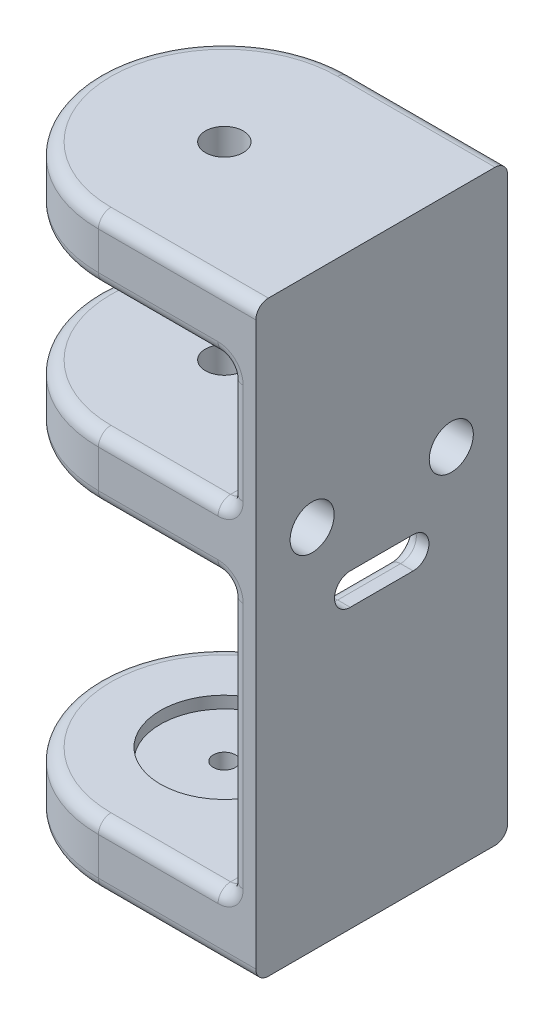
from build123d import *

# Parameters (mm, degrees)
SKETCH2_W           = 4
SKETCH2_H           = 40
BOSS_EXTRUDE1_DEPTH = 93.3
BOSS_EXTRUDE2_DEPTH = 10
SKETCH4_R           = 3
CUT_EXTRUDE4_DEPTH  = 10
SKETCH3_R           = 10.15
CUT_EXTRUDE3_DEPTH  = 1.9
SKETCH6_R           = 1.75
CUT_EXTRUDE6_DEPTH  = 9.1
FILLET2_R           = 2
SKETCH7_R           = 3.5
CUT_EXTRUDE7_DEPTH  = 6.1
CUT_EXTRUDE8_DEPTH  = 46
FILLET3_R           = 2


with BuildPart() as part:
    # Sketch2 → Boss-Extrude1 (new body)
    with BuildSketch(Plane(origin=(0, 0, 0), x_dir=(1, 0, 0), z_dir=(0, 1, 0))):
        Rectangle(SKETCH2_W, SKETCH2_H)
    extrude(amount=BOSS_EXTRUDE1_DEPTH)


with BuildPart() as body_2:
    # Sketch1 → Boss-Extrude2 (new body)
    with BuildSketch(Plane(origin=(0, 93.3, 0), x_dir=(1, 0, 0), z_dir=(0, 1, 0))):
        with BuildLine():
            Line((-23, -20), (-2, -20))
            Line((-2, -20), (-2, 20))
            Line((-2, 20), (-23, 20))
            ThreePointArc((-23, 20), (-43, 0), (-23, -20))
        make_face()
    boss_extrude2 = extrude(amount=-BOSS_EXTRUDE2_DEPTH)

    # Sketch4 → Cut-Extrude4 (cut)
    with BuildSketch(Plane(origin=(0, 93.3, 0), x_dir=(1, 0, 0), z_dir=(0, 1, 0))):
        with Locations((-23, 0)):
            Circle(SKETCH4_R)
    cut_extrude4 = extrude(amount=-CUT_EXTRUDE4_DEPTH, mode=Mode.SUBTRACT)


with BuildPart() as part_1:
    add(part.part)

    # Mirror8: Boss-Extrude2 across plane
    add(boss_extrude2.mirror(Plane.ZX.offset(46.65)))

    # Mirror10: Boss-Extrude2, Cut-Extrude4 across plane
    add(boss_extrude2.mirror(Plane.ZX.offset(73.3)))
    add(cut_extrude4.mirror(Plane.ZX.offset(73.3)), mode=Mode.SUBTRACT)


with BuildPart() as body_2_1:
    add(body_2.part)

    # Combine2: union part
    add(part_1.part)

    # Sketch3 → Cut-Extrude3 (cut)
    with BuildSketch(Plane(origin=(0, 10, 0), x_dir=(1, 0, 0), z_dir=(0, 1, 0))):
        with Locations((-23, 0)):
            Circle(SKETCH3_R)
    extrude(amount=-CUT_EXTRUDE3_DEPTH, mode=Mode.SUBTRACT)

    # Sketch6 → Cut-Extrude6 (cut, through all)
    with BuildSketch(Plane(origin=(0, 8.1, 0), x_dir=(1, 0, 0), z_dir=(0, 1, 0))):
        with Locations((-23, 0)):
            Circle(SKETCH6_R)
    extrude(amount=-CUT_EXTRUDE6_DEPTH, mode=Mode.SUBTRACT)

    # Fillet2
    fillet2_edges = [body_2_1.edges().sort_by_distance(p)[0] for p in [
        (-43, 83.3, 0),
        (-12.5, 83.3, 20),
        (-2, 73.3, -20),
        (-2, 53.3, 0),
        (-2, 31.65, -20),
        (-10.5, 0, -20),
        (-12.5, 53.3, -20),
        (-10.5, 0, 20),
        (-2, 73.3, 20),
        (-12.5, 53.3, 20),
        (-2, 31.65, 20),
        (-43, 0, 0),
        (-2, 10, 0),
        (-12.5, 10, -20),
        (-43, 10, 0),
        (-12.5, 10, 20),
        (-43, 53.3, 0),
        (-2, 63.3, 0),
        (-12.5, 63.3, -20),
        (-43, 63.3, 0),
        (-12.5, 63.3, 20),
        (-2, 83.3, 0),
        (-10.5, 93.3, 20),
        (-43, 93.3, 0),
        (-10.5, 93.3, -20),
        (-12.5, 83.3, -20),
    ]]
    fillet(fillet2_edges, radius=FILLET2_R)

    # Sketch7 → Cut-Extrude7 (cut)
    with BuildSketch(Plane(origin=(2, 0, 0), x_dir=(0, 0, -1), z_dir=(1, 0, 0))):
        with Locations((-11.05, 58.3)):
            Circle(SKETCH7_R)
        with Locations((11.05, 58.3)):
            Circle(SKETCH7_R)
    extrude(amount=-CUT_EXTRUDE7_DEPTH, mode=Mode.SUBTRACT)

    # Sketch8 → Cut-Extrude8 (cut, through all)
    with BuildSketch(Plane(origin=(2, 0, 0), x_dir=(0, 0, -1), z_dir=(1, 0, 0))):
        with BuildLine():
            Line((-5, 44.265), (5, 44.265))
            ThreePointArc((5, 44.265), (7.5, 46.765), (5, 49.265))
            Line((5, 49.265), (-5, 49.265))
            ThreePointArc((-5, 49.265), (-7.5, 46.765), (-5, 44.265))
        make_face()
    extrude(amount=-CUT_EXTRUDE8_DEPTH, mode=Mode.SUBTRACT)

    # Fillet3
    fillet3_edges = [body_2_1.edges().sort_by_distance(p)[0] for p in [
        (-2, 46.765, 7.5),
        (-2, 49.265, 0),
        (-2, 46.765, -7.5),
        (-2, 44.265, 0),
    ]]
    fillet(fillet3_edges, radius=FILLET3_R)


solid = body_2_1.part
